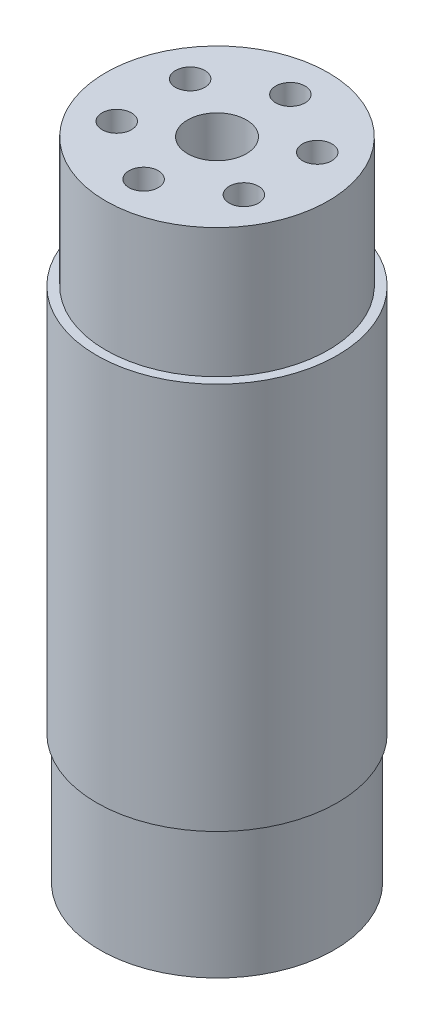
from build123d import *

# Parameters (mm, degrees)
ESQUISSE1_R             = 20.5
BOSS_EXTRU_1_DEPTH      = 110
ESQUISSE2_OUTSIDE_W     = 67.87
ESQUISSE2_OUTSIDE_H     = 67.87
ESQUISSE2_OUTSIDE_R     = 18.95
ENL_V_MAT_EXTRU_1_DEPTH = 22
ESQUISSE3_OUTSIDE_W     = 67.87
ESQUISSE3_OUTSIDE_H     = 67.87
ESQUISSE3_OUTSIDE_R     = 19.95
ENL_V_MAT_EXTRU_2_DEPTH = 22
ESQUISSE5_R             = 5
ENL_V_MAT_EXTRU_3_DEPTH = 111
ESQUISSE6_R             = 2.5
ENL_V_MAT_EXTRU_4_DEPTH = 50
ESQUISSE7_R             = 2.5
ENL_V_MAT_EXTRU_5_DEPTH = 50


with BuildPart() as part:
    # Esquisse1 → Boss.-Extru.1 (new body)
    with BuildSketch(Plane(origin=(0, 0, 0), x_dir=(1, 0, 0), z_dir=(0, 1, 0))):
        Circle(ESQUISSE1_R)
    extrude(amount=BOSS_EXTRU_1_DEPTH)

    # Esquisse2 outside → Enlèv. mat.-Extru.1 (cut)
    with BuildSketch(Plane(origin=(0, 110, 0), x_dir=(1, 0, 0), z_dir=(0, 1, 0))):
        Rectangle(ESQUISSE2_OUTSIDE_W, ESQUISSE2_OUTSIDE_H)
        Circle(ESQUISSE2_OUTSIDE_R, mode=Mode.SUBTRACT)
    extrude(amount=-ENL_V_MAT_EXTRU_1_DEPTH, mode=Mode.SUBTRACT)

    # Esquisse3 outside → Enlèv. mat.-Extru.2 (cut)
    with BuildSketch(Plane.XZ):
        Rectangle(ESQUISSE3_OUTSIDE_W, ESQUISSE3_OUTSIDE_H)
        Circle(ESQUISSE3_OUTSIDE_R, mode=Mode.SUBTRACT)
    extrude(amount=-ENL_V_MAT_EXTRU_2_DEPTH, mode=Mode.SUBTRACT)

    # Esquisse5 → Enlèv. mat.-Extru.3 (cut, through all)
    with BuildSketch(Plane(origin=(0, 110, 0), x_dir=(1, 0, 0), z_dir=(0, 1, 0))):
        Circle(ESQUISSE5_R)
    extrude(amount=-ENL_V_MAT_EXTRU_3_DEPTH, mode=Mode.SUBTRACT)

    # Esquisse6 → Enlèv. mat.-Extru.4 (cut)
    with BuildSketch(Plane(origin=(0, 110, 0), x_dir=(1, 0, 0), z_dir=(0, 1, 0))):
        with Locations((0, -12.5)):
            Circle(ESQUISSE6_R)
        with Locations((-10.825317547, -6.25)):
            Circle(ESQUISSE6_R)
        with Locations((-10.825317547, 6.25)):
            Circle(ESQUISSE6_R)
        with Locations((0, 12.5)):
            Circle(ESQUISSE6_R)
        with Locations((10.825317547, 6.25)):
            Circle(ESQUISSE6_R)
        with Locations((10.825317547, -6.25)):
            Circle(ESQUISSE6_R)
    extrude(amount=-ENL_V_MAT_EXTRU_4_DEPTH, mode=Mode.SUBTRACT)

    # Esquisse7 → Enlèv. mat.-Extru.5 (cut)
    with BuildSketch(Plane.XZ):
        with Locations((10.825317547, -6.25)):
            Circle(ESQUISSE7_R)
        with Locations((0, -12.5)):
            Circle(ESQUISSE7_R)
        with Locations((-10.825317547, -6.25)):
            Circle(ESQUISSE7_R)
        with Locations((-10.825317547, 6.25)):
            Circle(ESQUISSE7_R)
        with Locations((0, 12.5)):
            Circle(ESQUISSE7_R)
        with Locations((10.825317547, 6.25)):
            Circle(ESQUISSE7_R)
    extrude(amount=-ENL_V_MAT_EXTRU_5_DEPTH, mode=Mode.SUBTRACT)


solid = part.part
